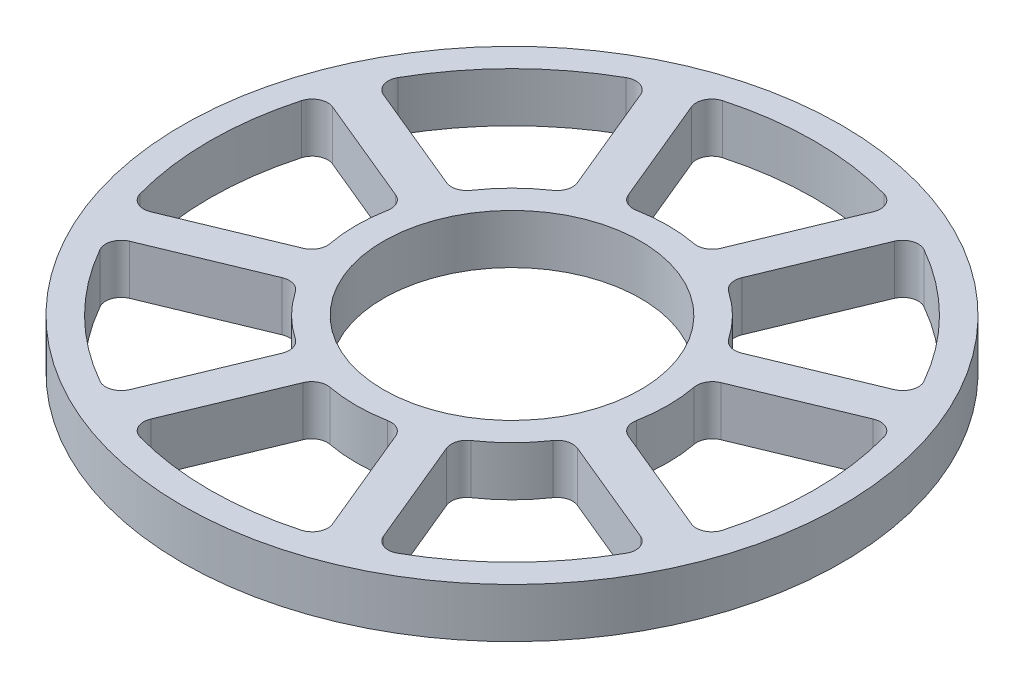
from build123d import *

# Parameters (mm, degrees)
SKETCH2_W                = 82.55
SKETCH2_H                = 12.7
CUT_EXTRUDE1_DEPTH       = 13.7
FILLET1_R                = 4
CIRPATTERN4_COUNT        = 8
FILLET1_OF_CIRPATTERN4_R = 4
SKETCH9_R                = 33
CUT_EXTRUDE2_DEPTH       = 13.7
SKETCH10_R               = 84.55
SKETCH10_R_2             = 82.55
BOSS_EXTRUDE1_DEPTH      = 12.7


with BuildPart() as part:
    # Sketch2 → Revolve1 (revolve)
    with BuildSketch(Plane(origin=(0, 0, 0), x_dir=(0, 0, -1), z_dir=(1, 0, 0))):
        with Locations((-41.275, 6.35)):
            Rectangle(SKETCH2_W, SKETCH2_H)
    revolve(axis=Axis((0, -0.5, 0), (0, 1, 0)))

    # Sketch8 → Cut-Extrude1 (cut, through all)
    with BuildSketch(Plane(origin=(0, 12.7, 0), x_dir=(1, 0, 0), z_dir=(0, 1, 0))):
        with BuildLine():
            Line((-10.567880231, 38.578749428), (-24.995954941, 73.411203073))
            ThreePointArc((-24.995954941, 73.411203073), (0, 77.55), (24.995954941, 73.411203073))
            Line((24.995954941, 73.411203073), (10.567880231, 38.578749428))
            ThreePointArc((10.567880231, 38.578749428), (0, 40), (-10.567880231, 38.578749428))
        make_face()
    cut_extrude1 = extrude(amount=-CUT_EXTRUDE1_DEPTH, mode=Mode.SUBTRACT)

    # Fillet1
    fillet1_edges = [part.edges().sort_by_distance(p)[0] for p in [
        (10.567880231, 6.35, -38.578749428),
        (-10.567880231, 6.35, -38.578749428),
        (-24.995954941, 6.35, -73.411203073),
        (24.995954941, 6.35, -73.411203073),
    ]]
    fillet(fillet1_edges, radius=FILLET1_R)

    # CirPattern4: Cut-Extrude1 ×8 about axis
    cirpattern4_axis = Axis((0, 0, 0), (0, 1, 0))
    for i in range(1, CIRPATTERN4_COUNT):
        add(cut_extrude1.rotate(cirpattern4_axis, i * 360 / CIRPATTERN4_COUNT), mode=Mode.SUBTRACT)

    # Fillet1 of CirPattern4
    fillet1_of_cirpattern4_edges = [part.edges().sort_by_distance(p)[0] for p in [
        (-19.806675556, 6.35, -34.751915104),
        (-34.751915104, 6.35, -19.806675556),
        (-69.584368749, 6.35, -34.234750266),
        (-34.234750266, 6.35, -69.584368749),
        (-38.578749428, 6.35, -10.567880231),
        (-38.578749428, 6.35, 10.567880231),
        (-73.411203073, 6.35, 24.995954941),
        (-73.411203073, 6.35, -24.995954941),
        (-34.751915104, 6.35, 19.806675556),
        (-19.806675556, 6.35, 34.751915104),
        (-34.234750266, 6.35, 69.584368749),
        (-69.584368749, 6.35, 34.234750266),
        (-10.567880231, 6.35, 38.578749428),
        (10.567880231, 6.35, 38.578749428),
        (24.995954941, 6.35, 73.411203073),
        (-24.995954941, 6.35, 73.411203073),
        (19.806675556, 6.35, 34.751915104),
        (34.751915104, 6.35, 19.806675556),
        (69.584368749, 6.35, 34.234750266),
        (34.234750266, 6.35, 69.584368749),
        (38.578749428, 6.35, 10.567880231),
        (38.578749428, 6.35, -10.567880231),
        (73.411203073, 6.35, -24.995954941),
        (73.411203073, 6.35, 24.995954941),
        (34.751915104, 6.35, -19.806675556),
        (19.806675556, 6.35, -34.751915104),
        (34.234750266, 6.35, -69.584368749),
        (69.584368749, 6.35, -34.234750266),
    ]]
    fillet(fillet1_of_cirpattern4_edges, radius=FILLET1_OF_CIRPATTERN4_R)

    # Sketch9 → Cut-Extrude2 (cut, through all)
    with BuildSketch(Plane(origin=(0, 12.7, 0), x_dir=(1, 0, 0), z_dir=(0, 1, 0))):
        Circle(SKETCH9_R)
    extrude(amount=-CUT_EXTRUDE2_DEPTH, mode=Mode.SUBTRACT)

    # Sketch10 → Boss-Extrude1 (add)
    with BuildSketch(Plane(origin=(0, 0, 0), x_dir=(1, 0, 0), z_dir=(0, 1, 0))):
        Circle(SKETCH10_R)
        Circle(SKETCH10_R_2, mode=Mode.SUBTRACT)
    extrude(amount=BOSS_EXTRUDE1_DEPTH)


solid = part.part
